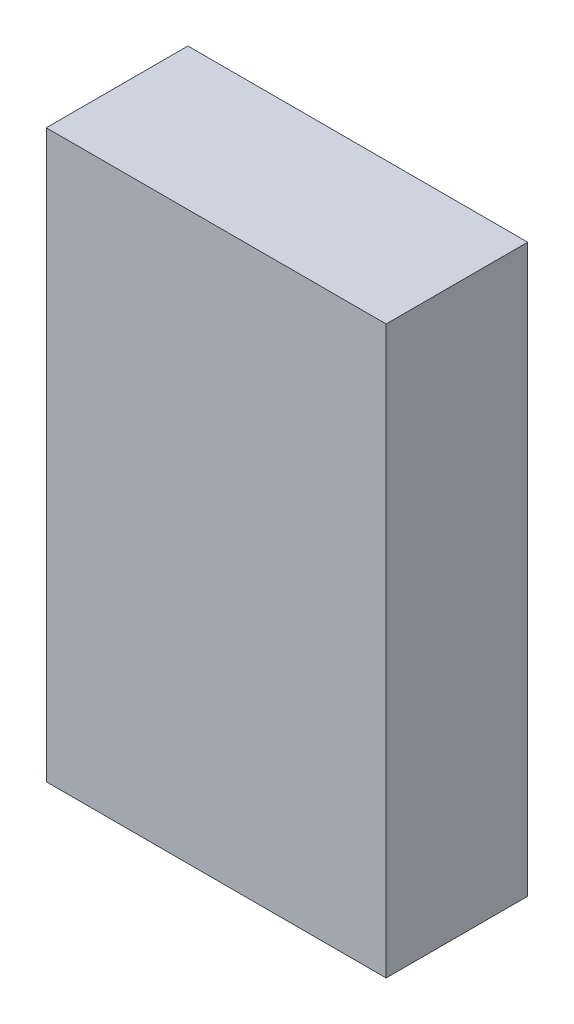
from build123d import *

# Parameters (mm, degrees)
SKETCH2_W           = 6
SKETCH2_H           = 10
BOSS_EXTRUDE3_DEPTH = 2.5


with BuildPart() as part:
    # Sketch2 → Boss-Extrude3 (new body)
    with BuildSketch(Plane.XY):
        with Locations((-5.536764706, 1.029411765)):
            Rectangle(SKETCH2_W, SKETCH2_H)
    extrude(amount=BOSS_EXTRUDE3_DEPTH)


solid = part.part
